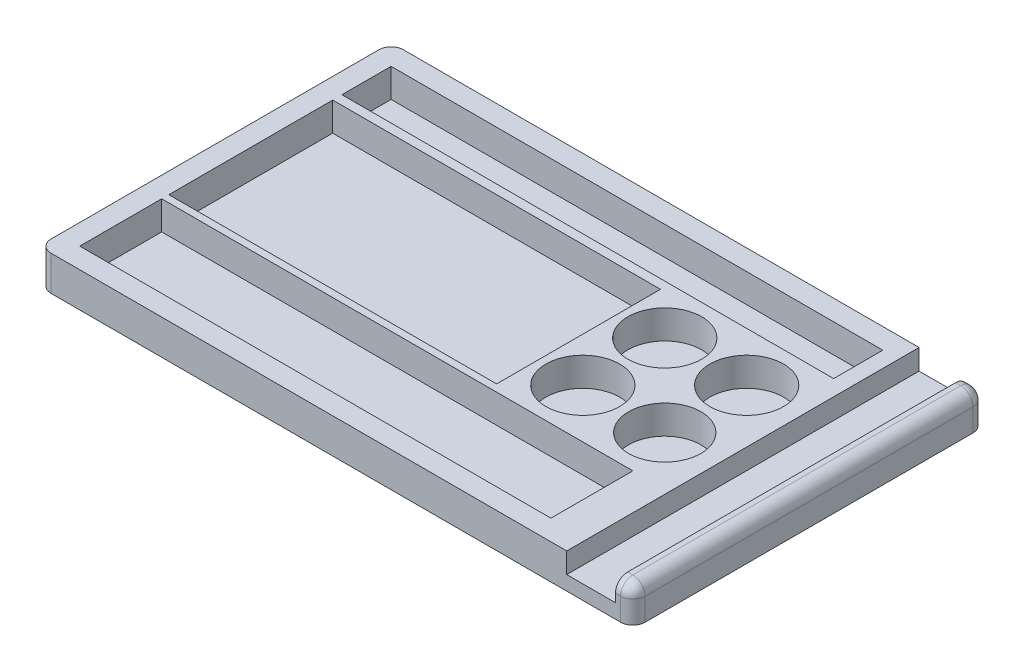
from build123d import *

# Parameters (mm, degrees)
SKETCH_1_W            = 145
SKETCH_1_H            = 86
EXTRUDE_305_DEPTH     = 8.5
SKETCH_4_W            = 80
SKETCH_4_H            = 40
CUT_EXTRUDE_1_DEPTH   = 7
SKETCH_6_W            = 115
SKETCH_6_H            = 20
CUT_EXTRUDE_793_DEPTH = 7
SKETCH_8_W            = 120
SKETCH_8_H            = 12
CUT_EXTRUDE_5_DEPTH   = 7
SKETCH_14_R           = 9
SKETCH_14_R_2         = 8.831298305
CUT_EXTRUDE_11_DEPTH  = 7
SKETCH_15_W           = 11.88767394
SKETCH_15_H           = 86
CUT_EXTRUDE_12_DEPTH  = 5
FILLET_1_R            = 3
FILLET_2_R            = 3
FILLET_3_R            = 3
FILLET_4_R            = 3
FILLET_5_R            = 3


with BuildPart() as part:
    # Эскиз1 → Extrude 305 (new body)
    with BuildSketch(Plane(origin=(0, 0, 0), x_dir=(1, 0, 0), z_dir=(0, 1, 0))):
        with Locations((72.5, 43)):
            Rectangle(SKETCH_1_W, SKETCH_1_H)
    extrude(amount=EXTRUDE_305_DEPTH)

    # Эскиз4 → Вырез-Вытянуть1 (cut)
    with BuildSketch(Plane(origin=(0, 8.5, 0), x_dir=(1, 0, 0), z_dir=(0, 1, 0))):
        with Locations((45, 46.740912533)):
            Rectangle(SKETCH_4_W, SKETCH_4_H)
    extrude(amount=-CUT_EXTRUDE_1_DEPTH, mode=Mode.SUBTRACT)

    # Эскиз6 → Cut-Extrude 793 (cut)
    with BuildSketch(Plane(origin=(0, 8.5, 0), x_dir=(1, 0, 0), z_dir=(0, 1, 0))):
        with Locations((62.5, 15)):
            Rectangle(SKETCH_6_W, SKETCH_6_H)
    extrude(amount=-CUT_EXTRUDE_793_DEPTH, mode=Mode.SUBTRACT)

    # Эскиз8 → Вырез-Вытянуть5 (cut)
    with BuildSketch(Plane(origin=(0, 8.5, 0), x_dir=(1, 0, 0), z_dir=(0, 1, 0))):
        with Locations((65, 75)):
            Rectangle(SKETCH_8_W, SKETCH_8_H)
    extrude(amount=-CUT_EXTRUDE_5_DEPTH, mode=Mode.SUBTRACT)

    # Эскиз14 → Вырез-Вытянуть11 (cut)
    with BuildSketch(Plane(origin=(0, 8.5, 0), x_dir=(1, 0, 0), z_dir=(0, 1, 0))):
        with Locations((95.807220746, 36.975666029)):
            Circle(SKETCH_14_R)
        with Locations((115.807220746, 36.975666029)):
            Circle(SKETCH_14_R_2)
        with Locations((95.807220746, 56.975666029)):
            Circle(SKETCH_14_R)
        with Locations((115.807220746, 56.975666029)):
            Circle(SKETCH_14_R)
    extrude(amount=-CUT_EXTRUDE_11_DEPTH, mode=Mode.SUBTRACT)

    # Эскиз15 → Вырез-Вытянуть12 (cut)
    with BuildSketch(Plane(origin=(0, 8.5, 0), x_dir=(1, 0, 0), z_dir=(0, 1, 0))):
        with Locations((134.800217128, 43)):
            Rectangle(SKETCH_15_W, SKETCH_15_H)
    extrude(amount=-CUT_EXTRUDE_12_DEPTH, mode=Mode.SUBTRACT)

    # Скругление1
    fillet_1_edges = [part.edges().sort_by_distance(p)[0] for p in [
        (145, 8.5, -43),
    ]]
    fillet(fillet_1_edges, radius=FILLET_1_R)

    # Скругление2
    fillet_2_edges = [part.edges().sort_by_distance(p)[0] for p in [
        (145, 2.75, 0),
        (144.121320344, 7.621320344, 0),
        (141.372027049, 8.5, 0),
    ]]
    fillet(fillet_2_edges, radius=FILLET_2_R)

    # Скругление3
    fillet_3_edges = [part.edges().sort_by_distance(p)[0] for p in [
        (141.372027049, 8.5, -86),
        (145, 2.75, -86),
        (144.121320344, 7.621320344, -86),
    ]]
    fillet(fillet_3_edges, radius=FILLET_3_R)

    # Скругление4
    fillet_4_edges = [part.edges().sort_by_distance(p)[0] for p in [
        (0, 4.25, 0),
    ]]
    fillet(fillet_4_edges, radius=FILLET_4_R)

    # Скругление5
    fillet_5_edges = [part.edges().sort_by_distance(p)[0] for p in [
        (0, 4.25, -86),
    ]]
    fillet(fillet_5_edges, radius=FILLET_5_R)


solid = part.part
